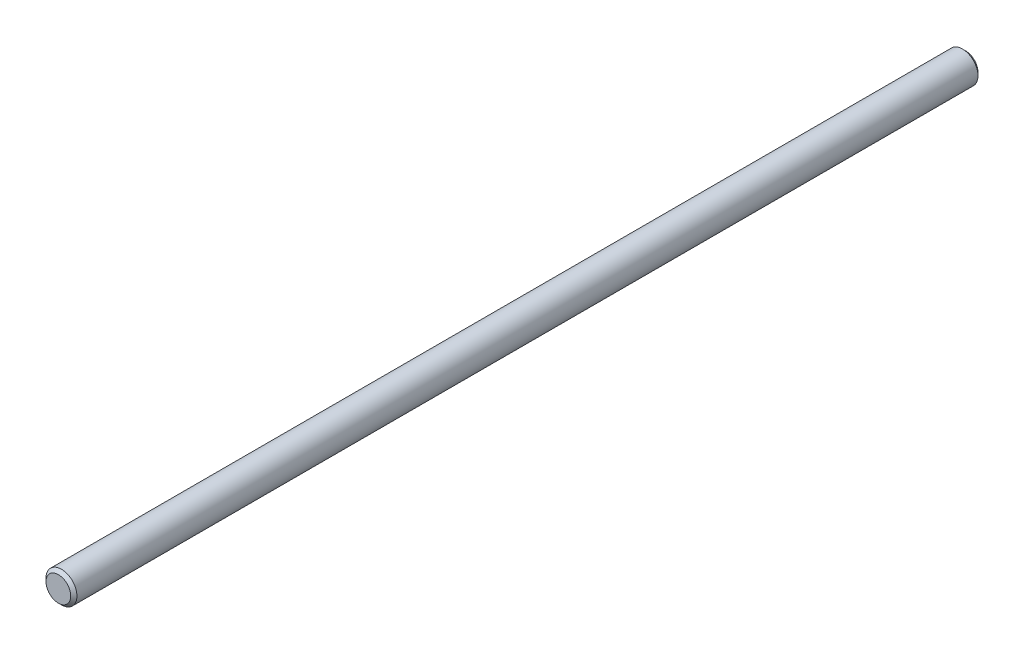
from build123d import *

# Parameters (mm, degrees)
SKETCH1_R      = 9.525
EXTRUDE1_DEPTH = 279.4
CHAMFER1_SIZE  = 1.905


with BuildPart() as part:
    # Sketch1 → Extrude1 (new body, symmetric)
    with BuildSketch(Plane.XY):
        Circle(SKETCH1_R)
    extrude(amount=EXTRUDE1_DEPTH, both=True)

    # Chamfer1
    chamfer1_edges = [part.edges().sort_by_distance(p)[0] for p in [
        (-9.525, 0, -279.4),
        (-9.525, 0, 279.4),
    ]]
    chamfer(chamfer1_edges, length=CHAMFER1_SIZE)


solid = part.part
